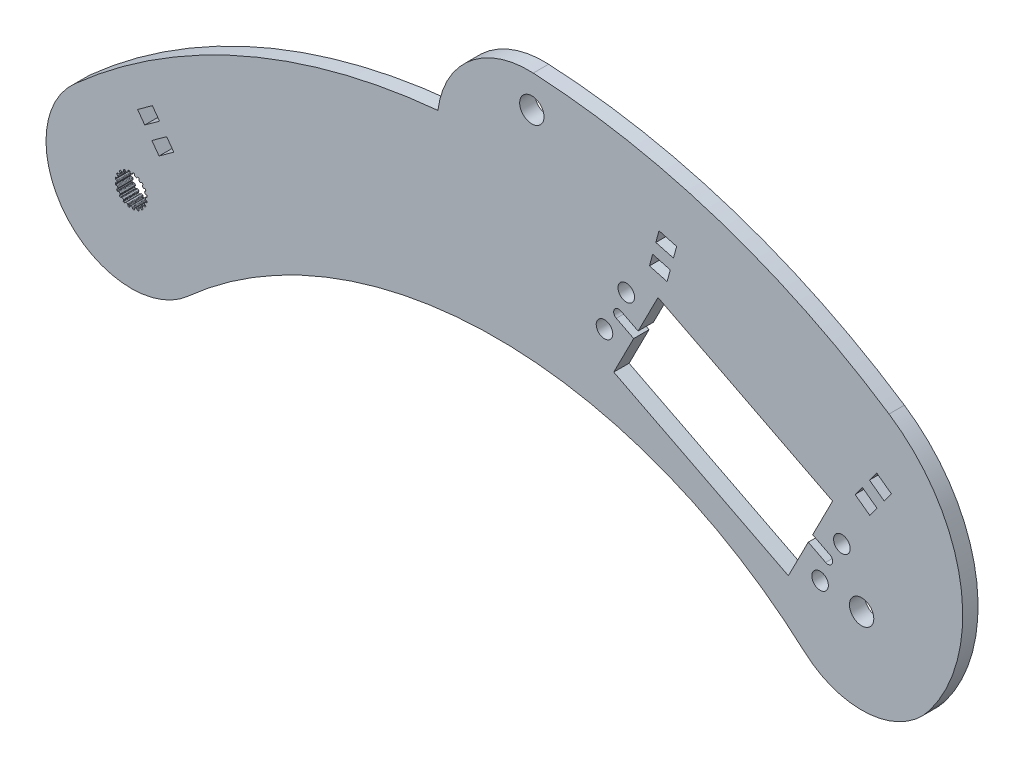
from build123d import *

# Parameters (mm, degrees)
BOSS_EXTRUDE1_DEPTH = 3.2004
SKETCH2_R           = 1.7272
SKETCH2_R_2         = 2.54
CUT_EXTRUDE1_DEPTH  = 3.2004
CUT_EXTRUDE2_DEPTH  = 3.2004
SKETCH4_R           = 2.54
BOSS_EXTRUDE2_DEPTH = 3.2004
CUT_EXTRUDE3_DEPTH  = 3.2004


with BuildPart() as part:
    # Sketch1 → Boss-Extrude1 (new body)
    with BuildSketch(Plane.XY):
        with BuildLine():
            ThreePointArc((-11.875315661, 13.236894431), (76.2, 46.954576728), (164.275315661, 13.236894431))
            ThreePointArc((164.275315661, 13.236894431), (165.636894431, -11.875315661), (140.524684339, -13.236894431))
            ThreePointArc((140.524684339, -13.236894431), (76.2, 11.388385128), (11.875315661, -13.236894431))
            ThreePointArc((11.875315661, -13.236894431), (-13.236894431, -11.875315661), (-11.875315661, 13.236894431))
        make_face()
        with BuildLine():
            Line((-0.106949245, 2.969874934), (0.106949245, 2.969874934))
            ThreePointArc((0.106949245, 2.969874934), (0.196343213, 2.986924176), (0.253739238, 3.057547504))
            Line((0.253739238, 3.057547504), (0.315888147, 3.237526941))
            ThreePointArc((0.315888147, 3.237526941), (0.359032156, 3.298322911), (0.4281449, 3.326269005))
            Line((0.4281449, 3.326269005), (0.620027588, 3.2937547))
            ThreePointArc((0.620027588, 3.2937547), (0.689621142, 3.24802576), (0.718272212, 3.169836791))
            Line((0.718272212, 3.169836791), (0.724389167, 2.979527391))
            ThreePointArc((0.724389167, 2.979527391), (0.750934762, 2.9040661), (0.816027049, 2.857568043))
            Line((0.816027049, 2.857568043), (1.019456602, 2.791469774))
            ThreePointArc((1.019456602, 2.791469774), (1.109743823, 2.780060312), (1.186154496, 2.829490741))
            Line((1.186154496, 2.829490741), (1.300878326, 2.981456288))
            ThreePointArc((1.300878326, 2.981456288), (1.360697704, 3.02594446), (1.435063648, 3.031165762))
            Line((1.435063648, 3.031165762), (1.607507455, 2.940947809))
            ThreePointArc((1.607507455, 2.940947809), (1.659563839, 2.875951412), (1.662650905, 2.792735615))
            Line((1.662650905, 2.792735615), (1.609659636, 2.609850378))
            ThreePointArc((1.609659636, 2.609850378), (1.611587176, 2.529879385), (1.659124931, 2.465542482))
            Line((1.659124931, 2.465542482), (1.832172444, 2.339816104))
            ThreePointArc((1.832172444, 2.339816104), (1.914514976, 2.301064775), (2.002460687, 2.32446371))
            Line((2.002460687, 2.32446371), (2.158529469, 2.433539921))
            ThreePointArc((2.158529469, 2.433539921), (2.229168681, 2.457365482), (2.301508367, 2.439350895))
            Line((2.301508367, 2.439350895), (2.437633293, 2.300260456))
            ThreePointArc((2.437633293, 2.300260456), (2.467056864, 2.222358901), (2.444277744, 2.14226202))
            Line((2.444277744, 2.14226202), (2.337365406, 1.984703026))
            ThreePointArc((2.337365406, 1.984703026), (2.314486209, 1.908050449), (2.339816104, 1.832172444))
            Line((2.339816104, 1.832172444), (2.465542482, 1.659124931))
            ThreePointArc((2.465542482, 1.659124931), (2.531880064, 1.596824985), (2.622752074, 1.591901975))
            Line((2.622752074, 1.591901975), (2.804888709, 1.64741171))
            ThreePointArc((2.804888709, 1.64741171), (2.879433095, 1.648242449), (2.942665411, 1.608755366))
            Line((2.942665411, 1.608755366), (3.0291466, 1.434407582))
            ThreePointArc((3.0291466, 1.434407582), (3.033057175, 1.351226417), (2.986641646, 1.282088892))
            Line((2.986641646, 1.282088892), (2.836273564, 1.165279113))
            ThreePointArc((2.836273564, 1.165279113), (2.790827206, 1.099448241), (2.791469774, 1.019456602))
            Line((2.791469774, 1.019456602), (2.857568043, 0.816027049))
            ThreePointArc((2.857568043, 0.816027049), (2.901407091, 0.736276839), (2.986310214, 0.703513784))
            Line((2.986310214, 0.703513784), (3.1766859, 0.700023363))
            ThreePointArc((3.1766859, 0.700023363), (3.247838536, 0.677777961), (3.295773863, 0.620683653))
            Line((3.295773863, 0.620683653), (3.324145932, 0.4281449))
            ThreePointArc((3.324145932, 0.4281449), (3.302160717, 0.347826477), (3.236652255, 0.29641597))
            Line((3.236652255, 0.29641597), (3.057547504, 0.231789562))
            ThreePointArc((3.057547504, 0.231789562), (2.993982591, 0.183224379), (2.969874934, 0.106949245))
            Line((2.969874934, 0.106949245), (2.969874934, -0.106949245))
            ThreePointArc((2.969874934, -0.106949245), (2.986924176, -0.196343213), (3.057547504, -0.253739238))
            Line((3.057547504, -0.253739238), (3.237526941, -0.315888147))
            ThreePointArc((3.237526941, -0.315888147), (3.298322911, -0.359032156), (3.326269005, -0.4281449))
            Line((3.326269005, -0.4281449), (3.2937547, -0.620027588))
            ThreePointArc((3.2937547, -0.620027588), (3.24802576, -0.689621142), (3.169836791, -0.718272212))
            Line((3.169836791, -0.718272212), (2.979527391, -0.724389167))
            ThreePointArc((2.979527391, -0.724389167), (2.9040661, -0.750934762), (2.857568043, -0.816027049))
            Line((2.857568043, -0.816027049), (2.791469774, -1.019456602))
            ThreePointArc((2.791469774, -1.019456602), (2.780060312, -1.109743823), (2.829490741, -1.186154496))
            Line((2.829490741, -1.186154496), (2.981456288, -1.300878326))
            ThreePointArc((2.981456288, -1.300878326), (3.02594446, -1.360697704), (3.031165762, -1.435063648))
            Line((3.031165762, -1.435063648), (2.940947809, -1.607507455))
            ThreePointArc((2.940947809, -1.607507455), (2.875951412, -1.659563839), (2.792735615, -1.662650905))
            Line((2.792735615, -1.662650905), (2.609850378, -1.609659636))
            ThreePointArc((2.609850378, -1.609659636), (2.529879385, -1.611587176), (2.465542482, -1.659124931))
            Line((2.465542482, -1.659124931), (2.339816104, -1.832172444))
            ThreePointArc((2.339816104, -1.832172444), (2.301064775, -1.914514976), (2.32446371, -2.002460687))
            Line((2.32446371, -2.002460687), (2.433539921, -2.158529469))
            ThreePointArc((2.433539921, -2.158529469), (2.457365482, -2.229168681), (2.439350895, -2.301508367))
            Line((2.439350895, -2.301508367), (2.300260456, -2.437633293))
            ThreePointArc((2.300260456, -2.437633293), (2.222358901, -2.467056864), (2.14226202, -2.444277744))
            Line((2.14226202, -2.444277744), (1.984703026, -2.337365406))
            ThreePointArc((1.984703026, -2.337365406), (1.908050449, -2.314486209), (1.832172444, -2.339816104))
            Line((1.832172444, -2.339816104), (1.659124931, -2.465542482))
            ThreePointArc((1.659124931, -2.465542482), (1.596824985, -2.531880064), (1.591901975, -2.622752074))
            Line((1.591901975, -2.622752074), (1.64741171, -2.804888709))
            ThreePointArc((1.64741171, -2.804888709), (1.648242449, -2.879433095), (1.608755366, -2.942665411))
            Line((1.608755366, -2.942665411), (1.434407582, -3.0291466))
            ThreePointArc((1.434407582, -3.0291466), (1.351226417, -3.033057175), (1.282088892, -2.986641646))
            Line((1.282088892, -2.986641646), (1.165279113, -2.836273564))
            ThreePointArc((1.165279113, -2.836273564), (1.099448241, -2.790827206), (1.019456602, -2.791469774))
            Line((1.019456602, -2.791469774), (0.816027049, -2.857568043))
            ThreePointArc((0.816027049, -2.857568043), (0.736276839, -2.901407091), (0.703513784, -2.986310214))
            Line((0.703513784, -2.986310214), (0.700023363, -3.1766859))
            ThreePointArc((0.700023363, -3.1766859), (0.677777961, -3.247838536), (0.620683653, -3.295773863))
            Line((0.620683653, -3.295773863), (0.4281449, -3.324145932))
            ThreePointArc((0.4281449, -3.324145932), (0.347826477, -3.302160717), (0.29641597, -3.236652255))
            Line((0.29641597, -3.236652255), (0.231789562, -3.057547504))
            ThreePointArc((0.231789562, -3.057547504), (0.183224379, -2.993982591), (0.106949245, -2.969874934))
            Line((0.106949245, -2.969874934), (-0.106949245, -2.969874934))
            ThreePointArc((-0.106949245, -2.969874934), (-0.196343213, -2.986924176), (-0.253739238, -3.057547504))
            Line((-0.253739238, -3.057547504), (-0.315888147, -3.237526941))
            ThreePointArc((-0.315888147, -3.237526941), (-0.359032156, -3.298322911), (-0.4281449, -3.326269005))
            Line((-0.4281449, -3.326269005), (-0.620027588, -3.2937547))
            ThreePointArc((-0.620027588, -3.2937547), (-0.689621142, -3.24802576), (-0.718272212, -3.169836791))
            Line((-0.718272212, -3.169836791), (-0.724389167, -2.979527391))
            ThreePointArc((-0.724389167, -2.979527391), (-0.750934762, -2.9040661), (-0.816027049, -2.857568043))
            Line((-0.816027049, -2.857568043), (-1.019456602, -2.791469774))
            ThreePointArc((-1.019456602, -2.791469774), (-1.109743823, -2.780060312), (-1.186154496, -2.829490741))
            Line((-1.186154496, -2.829490741), (-1.300878326, -2.981456288))
            ThreePointArc((-1.300878326, -2.981456288), (-1.360697704, -3.02594446), (-1.435063648, -3.031165762))
            Line((-1.435063648, -3.031165762), (-1.607507455, -2.940947809))
            ThreePointArc((-1.607507455, -2.940947809), (-1.659563839, -2.875951412), (-1.662650905, -2.792735615))
            Line((-1.662650905, -2.792735615), (-1.609659636, -2.609850378))
            ThreePointArc((-1.609659636, -2.609850378), (-1.611587176, -2.529879385), (-1.659124931, -2.465542482))
            Line((-1.659124931, -2.465542482), (-1.832172444, -2.339816104))
            ThreePointArc((-1.832172444, -2.339816104), (-1.914514976, -2.301064775), (-2.002460687, -2.32446371))
            Line((-2.002460687, -2.32446371), (-2.158529469, -2.433539921))
            ThreePointArc((-2.158529469, -2.433539921), (-2.229168681, -2.457365482), (-2.301508367, -2.439350895))
            Line((-2.301508367, -2.439350895), (-2.437633293, -2.300260456))
            ThreePointArc((-2.437633293, -2.300260456), (-2.467056864, -2.222358901), (-2.444277744, -2.14226202))
            Line((-2.444277744, -2.14226202), (-2.337365406, -1.984703026))
            ThreePointArc((-2.337365406, -1.984703026), (-2.314486209, -1.908050449), (-2.339816104, -1.832172444))
            Line((-2.339816104, -1.832172444), (-2.465542482, -1.659124931))
            ThreePointArc((-2.465542482, -1.659124931), (-2.531880064, -1.596824985), (-2.622752074, -1.591901975))
            Line((-2.622752074, -1.591901975), (-2.804888709, -1.64741171))
            ThreePointArc((-2.804888709, -1.64741171), (-2.879433095, -1.648242449), (-2.942665411, -1.608755366))
            Line((-2.942665411, -1.608755366), (-3.0291466, -1.434407582))
            ThreePointArc((-3.0291466, -1.434407582), (-3.033057175, -1.351226417), (-2.986641646, -1.282088892))
            Line((-2.986641646, -1.282088892), (-2.836273564, -1.165279113))
            ThreePointArc((-2.836273564, -1.165279113), (-2.790827206, -1.099448241), (-2.791469774, -1.019456602))
            Line((-2.791469774, -1.019456602), (-2.857568043, -0.816027049))
            ThreePointArc((-2.857568043, -0.816027049), (-2.901407091, -0.736276839), (-2.986310214, -0.703513784))
            Line((-2.986310214, -0.703513784), (-3.1766859, -0.700023363))
            ThreePointArc((-3.1766859, -0.700023363), (-3.247838536, -0.677777961), (-3.295773863, -0.620683653))
            Line((-3.295773863, -0.620683653), (-3.324145932, -0.4281449))
            ThreePointArc((-3.324145932, -0.4281449), (-3.302160717, -0.347826477), (-3.236652255, -0.29641597))
            Line((-3.236652255, -0.29641597), (-3.057547504, -0.231789562))
            ThreePointArc((-3.057547504, -0.231789562), (-2.993982591, -0.183224379), (-2.969874934, -0.106949245))
            Line((-2.969874934, -0.106949245), (-2.969874934, 0.106949245))
            ThreePointArc((-2.969874934, 0.106949245), (-2.986924176, 0.196343213), (-3.057547504, 0.253739238))
            Line((-3.057547504, 0.253739238), (-3.237526941, 0.315888147))
            ThreePointArc((-3.237526941, 0.315888147), (-3.298322911, 0.359032156), (-3.326269005, 0.4281449))
            Line((-3.326269005, 0.4281449), (-3.2937547, 0.620027588))
            ThreePointArc((-3.2937547, 0.620027588), (-3.24802576, 0.689621142), (-3.169836791, 0.718272212))
            Line((-3.169836791, 0.718272212), (-2.979527391, 0.724389167))
            ThreePointArc((-2.979527391, 0.724389167), (-2.9040661, 0.750934762), (-2.857568043, 0.816027049))
            Line((-2.857568043, 0.816027049), (-2.791469774, 1.019456602))
            ThreePointArc((-2.791469774, 1.019456602), (-2.780060312, 1.109743823), (-2.829490741, 1.186154496))
            Line((-2.829490741, 1.186154496), (-2.981456288, 1.300878326))
            ThreePointArc((-2.981456288, 1.300878326), (-3.02594446, 1.360697704), (-3.031165762, 1.435063648))
            Line((-3.031165762, 1.435063648), (-2.940947809, 1.607507455))
            ThreePointArc((-2.940947809, 1.607507455), (-2.875951412, 1.659563839), (-2.792735615, 1.662650905))
            Line((-2.792735615, 1.662650905), (-2.609850378, 1.609659636))
            ThreePointArc((-2.609850378, 1.609659636), (-2.529879385, 1.611587176), (-2.465542482, 1.659124931))
            Line((-2.465542482, 1.659124931), (-2.339816104, 1.832172444))
            ThreePointArc((-2.339816104, 1.832172444), (-2.301064775, 1.914514976), (-2.32446371, 2.002460687))
            Line((-2.32446371, 2.002460687), (-2.433539921, 2.158529469))
            ThreePointArc((-2.433539921, 2.158529469), (-2.457365482, 2.229168681), (-2.439350895, 2.301508367))
            Line((-2.439350895, 2.301508367), (-2.300260456, 2.437633293))
            ThreePointArc((-2.300260456, 2.437633293), (-2.222358901, 2.467056864), (-2.14226202, 2.444277744))
            Line((-2.14226202, 2.444277744), (-1.984703026, 2.337365406))
            ThreePointArc((-1.984703026, 2.337365406), (-1.908050449, 2.314486209), (-1.832172444, 2.339816104))
            Line((-1.832172444, 2.339816104), (-1.659124931, 2.465542482))
            ThreePointArc((-1.659124931, 2.465542482), (-1.596824985, 2.531880064), (-1.591901975, 2.622752074))
            Line((-1.591901975, 2.622752074), (-1.64741171, 2.804888709))
            ThreePointArc((-1.64741171, 2.804888709), (-1.648242449, 2.879433095), (-1.608755366, 2.942665411))
            Line((-1.608755366, 2.942665411), (-1.434407582, 3.0291466))
            ThreePointArc((-1.434407582, 3.0291466), (-1.351226417, 3.033057175), (-1.282088892, 2.986641646))
            Line((-1.282088892, 2.986641646), (-1.165279113, 2.836273564))
            ThreePointArc((-1.165279113, 2.836273564), (-1.099448241, 2.790827206), (-1.019456602, 2.791469774))
            Line((-1.019456602, 2.791469774), (-0.816027049, 2.857568043))
            ThreePointArc((-0.816027049, 2.857568043), (-0.736276839, 2.901407091), (-0.703513784, 2.986310214))
            Line((-0.703513784, 2.986310214), (-0.700023363, 3.1766859))
            ThreePointArc((-0.700023363, 3.1766859), (-0.677777961, 3.247838536), (-0.620683653, 3.295773863))
            Line((-0.620683653, 3.295773863), (-0.4281449, 3.324145932))
            ThreePointArc((-0.4281449, 3.324145932), (-0.347826477, 3.302160717), (-0.29641597, 3.236652255))
            Line((-0.29641597, 3.236652255), (-0.231789562, 3.057547504))
            ThreePointArc((-0.231789562, 3.057547504), (-0.183224379, 2.993982591), (-0.106949245, 2.969874934))
        make_face(mode=Mode.SUBTRACT)
    extrude(amount=BOSS_EXTRUDE1_DEPTH)

    # Sketch2 → Cut-Extrude1 (cut)
    with BuildSketch(Plane.XY.offset(3.2004)):
        with Locations((103.294155033, 33.130546269)):
            Circle(SKETCH2_R)
        with Locations((143.733546084, 1.272962356)):
            Circle(SKETCH2_R)
        with Locations((148.278076154, 10.180669567)):
            Circle(SKETCH2_R)
        with Locations((98.749624963, 24.222839057)):
            Circle(SKETCH2_R)
        with Locations((152.4, 0)):
            Circle(SKETCH2_R_2)
        Polygon((109.917504264, 35.544185352), (146.344681894, 16.959784207), (137.110196853, -1.140676727), (100.683019223, 17.443724418), align=None)
    extrude(amount=-CUT_EXTRUDE1_DEPTH, mode=Mode.SUBTRACT)

    # Sketch3 → Cut-Extrude2 (cut)
    with BuildSketch(Plane.XY.offset(3.2004)):
        with BuildLine():
            Line((102.141893809, 29.24587494), (105.761985996, 27.398977932))
            Line((105.761985996, 27.398977932), (104.838537492, 25.588931838))
            Line((104.838537492, 25.588931838), (101.218445305, 27.435828846))
            ThreePointArc((101.218445305, 27.435828846), (100.77514651, 28.802576145), (102.141893809, 29.24587494))
        make_face()
        with BuildLine():
            Line((142.189163626, 8.814576786), (145.809255813, 6.967679778))
            ThreePointArc((145.809255813, 6.967679778), (146.252554607, 5.60093248), (144.885807308, 5.157633685))
            Line((144.885807308, 5.157633685), (141.265715122, 7.004530693))
            Line((141.265715122, 7.004530693), (142.189163626, 8.814576786))
        make_face()
    extrude(amount=-CUT_EXTRUDE2_DEPTH, mode=Mode.SUBTRACT)

    # Sketch4 → Boss-Extrude2 (add)
    with BuildSketch(Plane.XY.offset(3.2004)):
        with BuildLine():
            ThreePointArc((63.994452175, 46.388596865), (70.655775204, 58.652872993), (83.889992464, 63.08471087))
            ThreePointArc((83.889992464, 63.08471087), (122.650665385, 55.817735997), (158.123143389, 38.586891754))
            ThreePointArc((158.123143389, 38.586891754), (172.994139846, 15.795725761), (166.631162232, -10.663607165))
            ThreePointArc((166.631162232, -10.663607165), (170.097331469, 1.744406806), (164.275315661, 13.236894431))
            ThreePointArc((164.275315661, 13.236894431), (117.598239835, 40.289080087), (63.994452175, 46.388596865))
        make_face()
        with Locations((83.588077125, 56.286137461)):
            Circle(SKETCH4_R, mode=Mode.SUBTRACT)
    extrude(amount=-BOSS_EXTRUDE2_DEPTH)

    # Sketch5 → Cut-Extrude3 (cut)
    with BuildSketch(Plane(origin=(0, 0, 0), x_dir=(-1, 0, 0), z_dir=(0, 0, -1))):
        Polygon((-113.802519463, 46.720594144), (-110.12480818, 47.715852764), (-109.461302433, 45.264045242), (-113.139013716, 44.268786622), align=None)
        Polygon((-112.47550797, 41.8169791), (-108.797796687, 42.81223772), (-108.134290941, 40.360430198), (-111.812002223, 39.365171578), align=None)
        Polygon((-155.533693444, 26.659723858), (-158.607972247, 24.409188402), (-157.107615276, 22.3596692), (-154.033336473, 24.610204656), align=None)
        Polygon((-155.607258305, 20.310149998), (-152.532979502, 22.560685454), (-151.032622531, 20.511166252), (-154.106901334, 18.260630795), align=None)
        Polygon((-2.821637872, 13.16701556), (-5.907729433, 15.401325046), (-4.418189775, 17.45871942), (-1.332098215, 15.224409934), align=None)
        Polygon((-5.800717187, 9.052226813), (-8.886808747, 11.286536299), (-7.39726909, 13.343930673), (-4.311177529, 11.109621187), align=None)
    extrude(amount=-CUT_EXTRUDE3_DEPTH, mode=Mode.SUBTRACT)


solid = part.part
